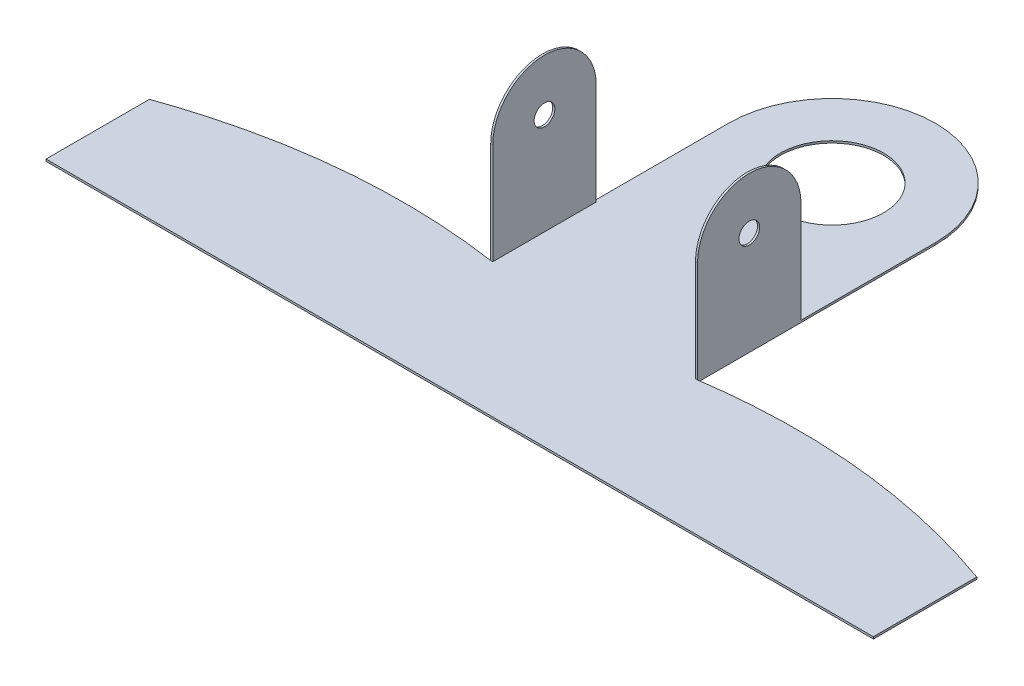
from build123d import *

# Parameters (mm, degrees)
SKETCH_1_R      = 5
EXTRUDE_1_DEPTH = 0.1
SKETCH_3_R      = 1
EXTRUDE_2_DEPTH = 0.2
SKETCH_4_R      = 1
EXTRUDE_3_DEPTH = 0.2


with BuildPart() as part:
    # 草图1 → 凸台-拉伸1 (new body, symmetric)
    with BuildSketch(Plane(origin=(0, 0, 0), x_dir=(1, 0, 0), z_dir=(0, 1, 0))):
        with BuildLine():
            Line((10, 0), (10, -23))
            add(Edge.make_bspline(
                [(10, -23), (25.285299712, -20.780872621), (40, -26)],
                knots=[0, 0, 0, 1, 1, 1], degree=2))
            Line((40, -26), (40, -36))
            Line((40, -36), (-40, -36))
            Line((-40, -36), (-40, -26))
            add(Edge.make_bspline(
                [(-10, -23), (-25.285299712, -20.780872621), (-40, -26)],
                knots=[0, 0, 0, 1, 1, 1], degree=2))
            Line((-10, -23), (-10, 0))
            ThreePointArc((-10, 0), (0, 10), (10, 0))
        make_face()
        Circle(SKETCH_1_R, mode=Mode.SUBTRACT)
    extrude(amount=EXTRUDE_1_DEPTH, both=True)

    # 草图3 → 凸台-拉伸2 (add)
    with BuildSketch(Plane(origin=(10, 0, 0), x_dir=(0, 0, -1), z_dir=(1, 0, 0))):
        with BuildLine():
            Line((-23, -0.1), (-13, -0.1))
            Line((-13, -0.1), (-13, 9.9))
            ThreePointArc((-13, 9.9), (-18, 14.9), (-23, 9.9))
            Line((-23, 9.9), (-23, -0.1))
        make_face()
        with Locations((-18, 9.9)):
            Circle(SKETCH_3_R, mode=Mode.SUBTRACT)
    extrude(amount=-EXTRUDE_2_DEPTH)

    # 草图4 → 凸台-拉伸3 (add)
    with BuildSketch(Plane.ZY.offset(10)):
        with BuildLine():
            Line((23, -0.1), (13, -0.1))
            Line((13, -0.1), (13, 9.9))
            ThreePointArc((13, 9.9), (18, 14.9), (23, 9.9))
            Line((23, 9.9), (23, -0.1))
        make_face()
        with Locations((18, 9.9)):
            Circle(SKETCH_4_R, mode=Mode.SUBTRACT)
    extrude(amount=-EXTRUDE_3_DEPTH)


solid = part.part
